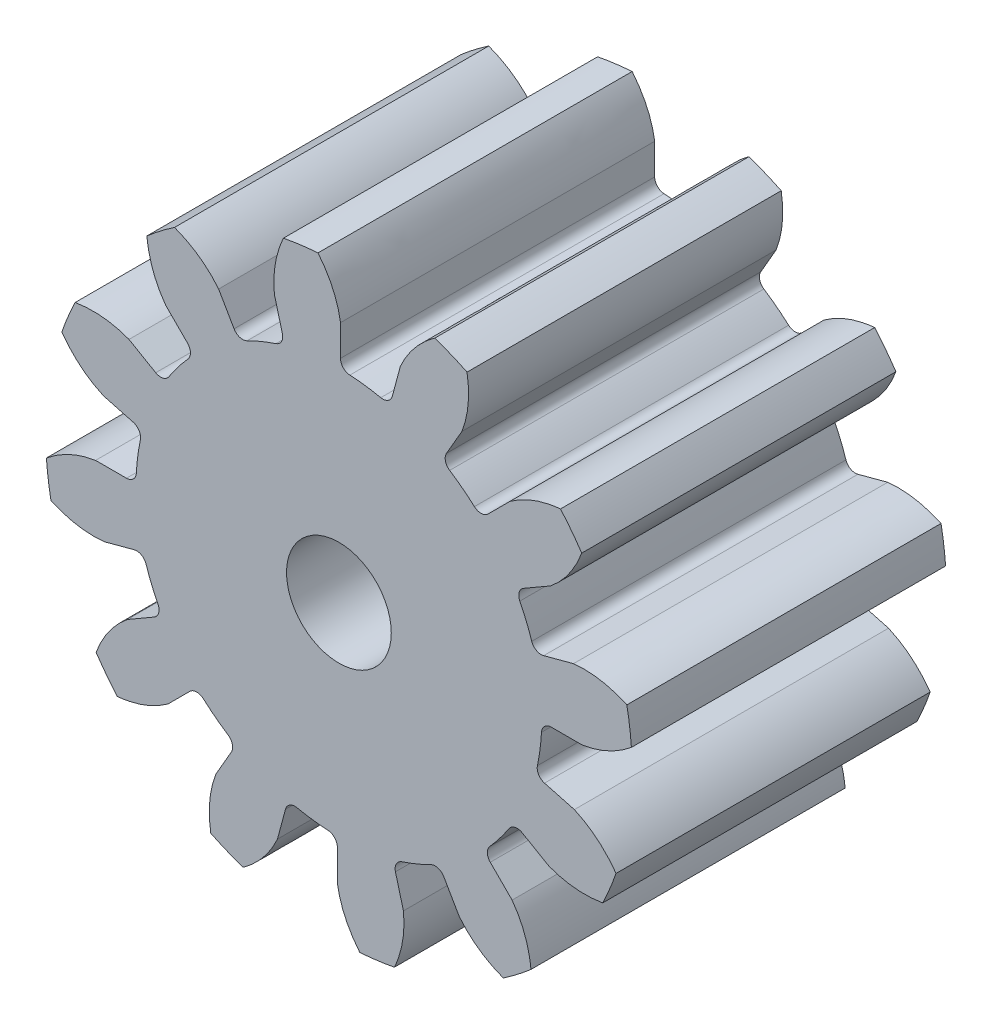
from build123d import *

# Parameters (mm, degrees)
SKETCH1_R                = 8.89
BOSS_EXTRUDE1_DEPTH      = 9.525
CUT_EXTRUDE1_DEPTH       = 10.525
FILLET1_R                = 0.2992374
CIRPATTERN1_COUNT        = 12
FILLET1_OF_CIRPATTERN1_R = 0.2992374
SKETCH5_R                = 1.5875
CUT_EXTRUDE2_DEPTH       = 10.5250049


with BuildPart() as part:
    # Sketch1 → Boss-Extrude1 (new body)
    with BuildSketch(Plane.XY):
        Circle(SKETCH1_R)
    extrude(amount=-BOSS_EXTRUDE1_DEPTH)

    # Sketch4 → Cut-Extrude1 (cut, through all)
    with BuildSketch(Plane.XY):
        with BuildLine():
            Line((0.04830876, 7.377126848), (0.04830876, 6.150420281))
            ThreePointArc((0.04830876, 6.150420281), (0.80281757, 6.097990433), (1.54518687, 5.953352073))
            Line((1.54518687, 5.953352073), (1.862682618, 7.138259433))
            add(Edge.make_bspline(
                [(2.921760286, 8.411131642), (2.200093057, 7.899390383), (1.862682618, 7.138259433)],
                knots=[0, 0, 0, 1, 1, 1], degree=2))
            ThreePointArc((2.921760286, 8.411131642), (1.162226994, 8.82796959), (-0.645237222, 8.880736884))
            add(Edge.make_bspline(
                [(-0.645237222, 8.880736884), (-0.080609008, 8.199651217), (0.04830876, 7.377126848)],
                knots=[0, 0, 0, 1, 1, 1], degree=2))
        make_face()
    cut_extrude1 = extrude(amount=-CUT_EXTRUDE1_DEPTH, mode=Mode.SUBTRACT)

    # Fillet1
    fillet1_edges = [part.edges().sort_by_distance(p)[0] for p in [
        (1.54518687, 5.953352073, -4.7625),
        (0.04830876, 6.150420281, -4.7625),
    ]]
    fillet(fillet1_edges, radius=FILLET1_R)

    # CirPattern1: Cut-Extrude1 ×12 about axis
    cirpattern1_axis = Axis((0, 0, -9.525), (0, 0, 1))
    for i in range(1, CIRPATTERN1_COUNT):
        add(cut_extrude1.rotate(cirpattern1_axis, i * 360 / CIRPATTERN1_COUNT), mode=Mode.SUBTRACT)

    # Fillet1 of CirPattern1
    fillet1_of_cirpattern1_edges = [part.edges().sort_by_distance(p)[0] for p in [
        (-1.638504953, 5.928347568, -4.7625),
        (-3.033373527, 5.350574587, -4.7625),
        (-4.383160698, 4.31484712, -4.7625),
        (-5.302265828, 3.117046754, -4.7625),
        (-5.953352073, 1.54518687, -4.7625),
        (-6.150420281, 0.04830876, -4.7625),
        (-5.928347568, -1.638504953, -4.7625),
        (-5.350574587, -3.033373527, -4.7625),
        (-4.31484712, -4.383160698, -4.7625),
        (-3.117046754, -5.302265828, -4.7625),
        (-1.54518687, -5.953352073, -4.7625),
        (-0.04830876, -6.150420281, -4.7625),
        (1.638504953, -5.928347568, -4.7625),
        (3.033373527, -5.350574587, -4.7625),
        (4.383160698, -4.31484712, -4.7625),
        (5.302265828, -3.117046754, -4.7625),
        (5.953352073, -1.54518687, -4.7625),
        (6.150420281, -0.04830876, -4.7625),
        (5.928347568, 1.638504953, -4.7625),
        (5.350574587, 3.033373527, -4.7625),
        (4.31484712, 4.383160698, -4.7625),
        (3.117046754, 5.302265828, -4.7625),
    ]]
    fillet(fillet1_of_cirpattern1_edges, radius=FILLET1_OF_CIRPATTERN1_R)

    # Sketch5 → Cut-Extrude2 (cut, through all)
    with BuildSketch(Plane.XY):
        Circle(SKETCH5_R)
    extrude(amount=-CUT_EXTRUDE2_DEPTH, mode=Mode.SUBTRACT)


solid = part.part
